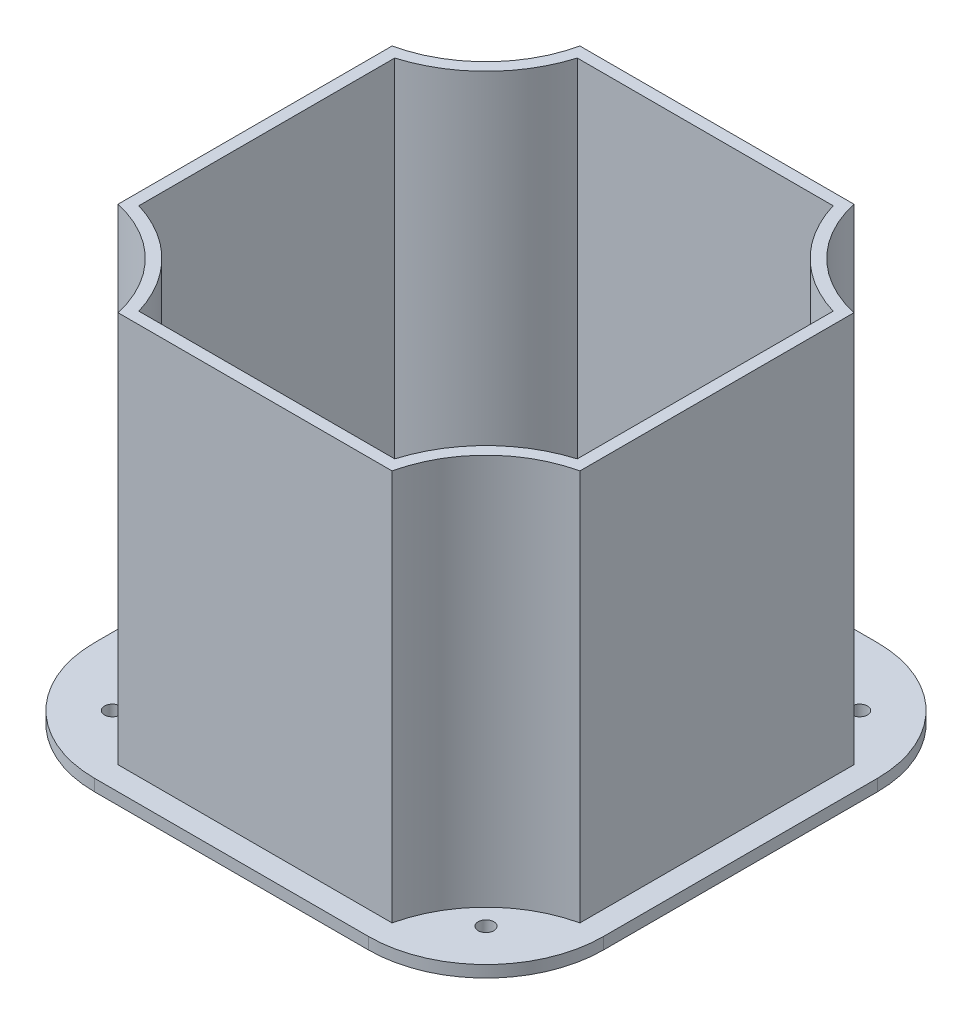
from build123d import *

# Parameters (mm, degrees)
SKETCH1_R                = 1
BOSS_EXTRUDE1_DEPTH      = 1.5
BOSS_EXTRUDE2_DEPTH      = 50
BOSS_EXTRUDE2_DEPTH_BACK = 1.5


with BuildPart() as part:
    # Sketch1 → Boss-Extrude1 (new body)
    with BuildSketch(Plane(origin=(0, 0, 0), x_dir=(1, 0, 0), z_dir=(0, 1, 0))):
        with BuildLine():
            Line((33.535245878, -16.168969585), (33.535245878, 18.831030415))
            ThreePointArc((33.535245878, 18.831030415), (29.141847596, 29.437632132), (18.535245878, 33.831030415))
            Line((18.535245878, 33.831030415), (-16.464754122, 33.831030415))
            ThreePointArc((-16.464754122, 33.831030415), (-27.07135584, 29.437632132), (-31.464754122, 18.831030415))
            Line((-31.464754122, 18.831030415), (-31.464754122, -16.168969585))
            ThreePointArc((-31.464754122, -16.168969585), (-27.07135584, -26.775571303), (-16.464754122, -31.168969585))
            Line((-16.464754122, -31.168969585), (18.535245878, -31.168969585))
            ThreePointArc((18.535245878, -31.168969585), (29.141847596, -26.775571303), (33.535245878, -16.168969585))
        make_face()
        with Locations((24.899206909, -22.532930616)):
            Circle(SKETCH1_R, mode=Mode.SUBTRACT)
        with Locations((-22.828715153, -22.532930616)):
            Circle(SKETCH1_R, mode=Mode.SUBTRACT)
        with Locations((-22.828715153, 25.194991445)):
            Circle(SKETCH1_R, mode=Mode.SUBTRACT)
        with Locations((24.899206909, 25.194991445)):
            Circle(SKETCH1_R, mode=Mode.SUBTRACT)
        with BuildLine():
            Line((18.535245878, -28.168969585), (-16.464754122, -28.168969585))
            ThreePointArc((-16.464754122, -28.168969585), (-20.723457919, -20.427673383), (-28.464754122, -16.168969585))
            Line((-28.464754122, -16.168969585), (-28.464754122, 18.831030415))
            ThreePointArc((-28.464754122, 18.831030415), (-20.723457919, 23.089734212), (-16.464754122, 30.831030415))
            Line((-16.464754122, 30.831030415), (18.535245878, 30.831030415))
            ThreePointArc((18.535245878, 30.831030415), (22.793949675, 23.089734212), (30.535245878, 18.831030415))
            Line((30.535245878, 18.831030415), (30.535245878, -16.168969585))
            ThreePointArc((30.535245878, -16.168969585), (22.793949675, -20.427673383), (18.535245878, -28.168969585))
        make_face(mode=Mode.SUBTRACT)
    extrude(amount=BOSS_EXTRUDE1_DEPTH)

    # Sketch2 → Boss-Extrude2 (add, two sides)
    with BuildSketch(Plane(origin=(0, 1.5, 0), x_dir=(1, 0, 0), z_dir=(0, 1, 0))) as boss_extrude2_sk:
        with BuildLine():
            Line((-28.464754122, 18.831030415), (-28.464754122, -16.168969585))
            ThreePointArc((-28.464754122, -16.168969585), (-20.723457919, -20.427673383), (-16.464754122, -28.168969585))
            Line((-16.464754122, -28.168969585), (18.535245878, -28.168969585))
            ThreePointArc((18.535245878, -28.168969585), (22.793949675, -20.427673383), (30.535245878, -16.168969585))
            Line((30.535245878, -16.168969585), (30.535245878, 18.831030415))
            ThreePointArc((30.535245878, 18.831030415), (22.793949675, 23.089734212), (18.535245878, 30.831030415))
            Line((18.535245878, 30.831030415), (-16.464754122, 30.831030415))
            ThreePointArc((-16.464754122, 30.831030415), (-20.723457919, 23.089734212), (-28.464754122, 18.831030415))
        make_face()
        with BuildLine():
            Line((29.035245878, -15.01127646), (29.035245878, 17.673337289))
            ThreePointArc((29.035245878, 17.673337289), (21.733289504, 22.02907404), (17.377552753, 29.331030415))
            Line((17.377552753, 29.331030415), (-15.307060997, 29.331030415))
            ThreePointArc((-15.307060997, 29.331030415), (-19.662797748, 22.02907404), (-26.964754122, 17.673337289))
            Line((-26.964754122, 17.673337289), (-26.964754122, -15.01127646))
            ThreePointArc((-26.964754122, -15.01127646), (-19.662797748, -19.367013211), (-15.307060997, -26.668969585))
            Line((-15.307060997, -26.668969585), (17.377552753, -26.668969585))
            ThreePointArc((17.377552753, -26.668969585), (21.733289504, -19.367013211), (29.035245878, -15.01127646))
        make_face(mode=Mode.SUBTRACT)
    extrude(amount=BOSS_EXTRUDE2_DEPTH)
    extrude(boss_extrude2_sk.sketch, amount=-BOSS_EXTRUDE2_DEPTH_BACK)


solid = part.part
